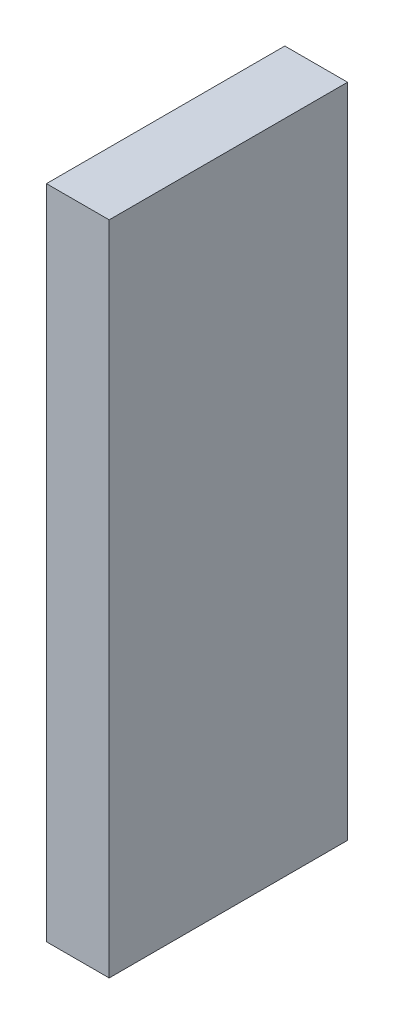
from build123d import *

# Parameters (mm, degrees)
SKETCH1_W           = 15
SKETCH1_H           = 157
BOSS_EXTRUDE1_DEPTH = 57


with BuildPart() as part:
    # Sketch1 → Boss-Extrude1 (new body)
    with BuildSketch(Plane.XY):
        with Locations((7.5, 78.5)):
            Rectangle(SKETCH1_W, SKETCH1_H)
    extrude(amount=BOSS_EXTRUDE1_DEPTH)


solid = part.part
